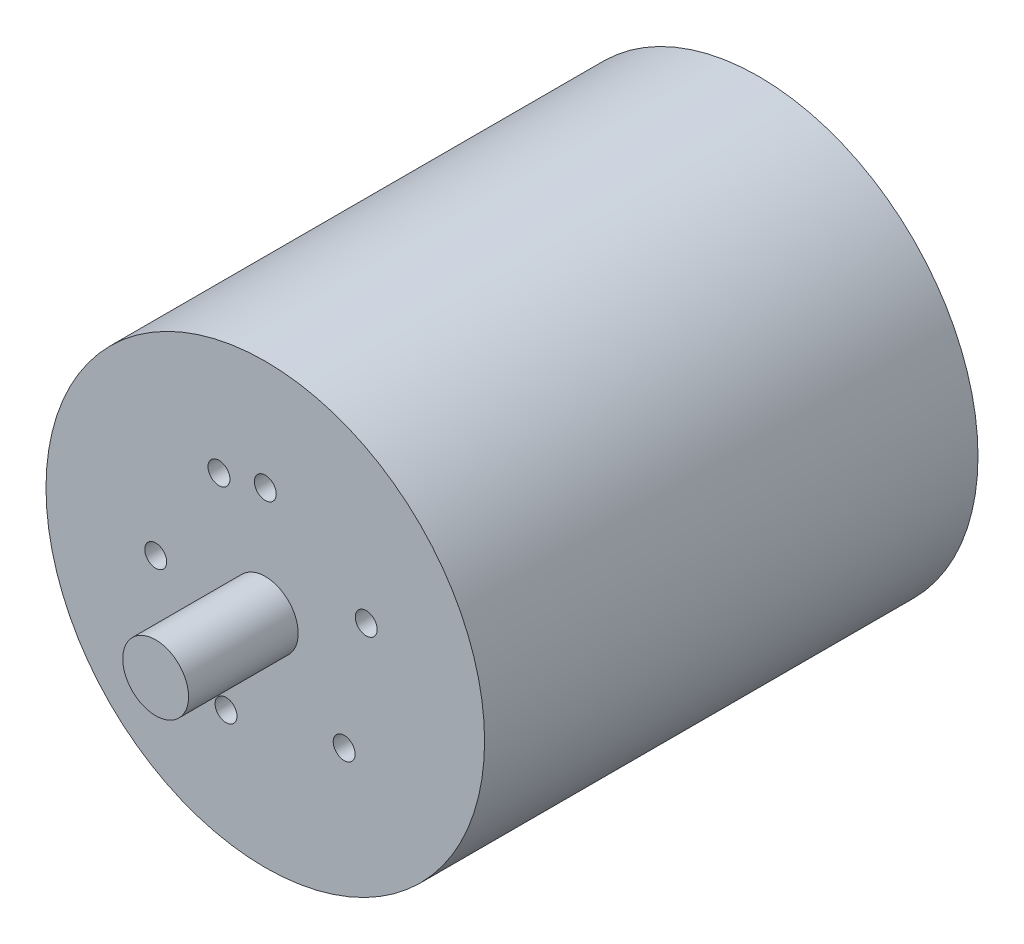
from build123d import *

# Parameters (mm, degrees)
SKETCH1_R           = 20
BOSS_EXTRUDE1_DEPTH = 22.5
SKETCH2_R           = 3
BOSS_EXTRUDE2_DEPTH = 10
SKETCH3_R           = 1
CUT_EXTRUDE1_DEPTH  = 2
CIRPATTERN1_COUNT   = 6
CIRPATTERN1_ANGLE   = 335


with BuildPart() as part:
    # Sketch1 → Boss-Extrude1 (new body, symmetric)
    with BuildSketch(Plane.XY):
        Circle(SKETCH1_R)
    extrude(amount=BOSS_EXTRUDE1_DEPTH, both=True)

    # Sketch2 → Boss-Extrude2 (add)
    with BuildSketch(Plane.XY.offset(22.5)):
        Circle(SKETCH2_R)
    extrude(amount=BOSS_EXTRUDE2_DEPTH)

    # Sketch3 → Cut-Extrude1 (cut)
    with BuildSketch(Plane.XY.offset(22.5)):
        with Locations((0, 10)):
            Circle(SKETCH3_R)
    cut_extrude1 = extrude(amount=-CUT_EXTRUDE1_DEPTH, mode=Mode.SUBTRACT)

    # CirPattern1: Cut-Extrude1 ×6 about axis
    cirpattern1_axis = Axis((0, 0, 0), (0, 0, -1))
    for i in range(1, CIRPATTERN1_COUNT):
        add(cut_extrude1.rotate(cirpattern1_axis, i * CIRPATTERN1_ANGLE / (CIRPATTERN1_COUNT - 1)), mode=Mode.SUBTRACT)


solid = part.part
